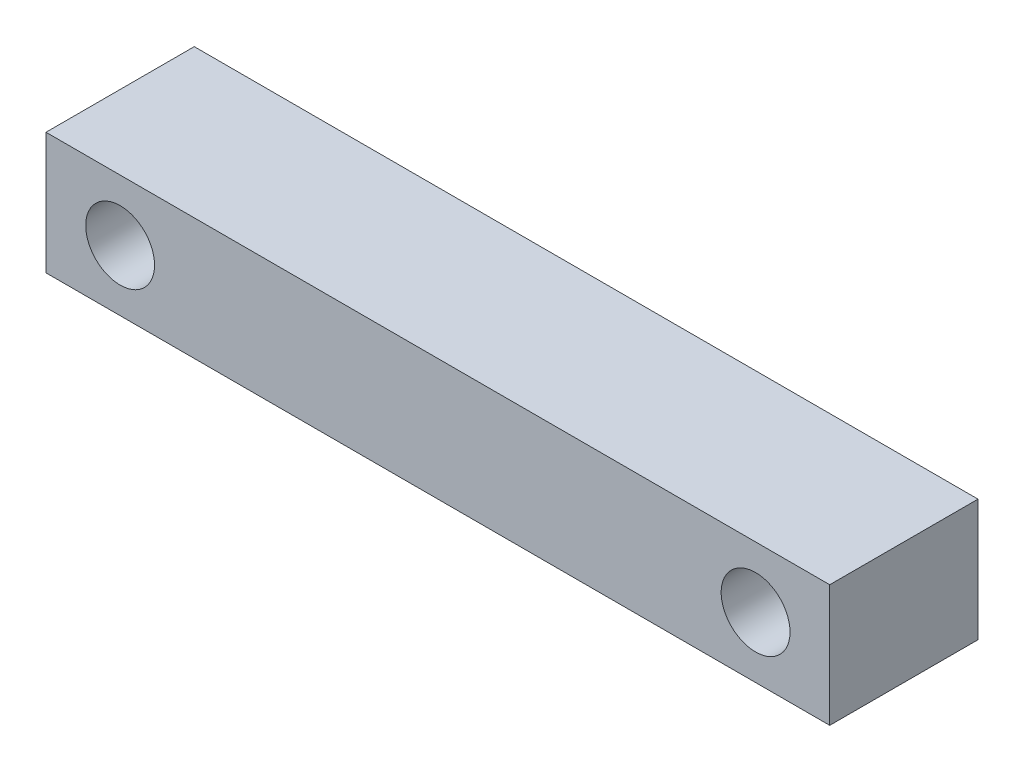
from build123d import *

# Parameters (mm, degrees)
SKETCH1_W      = 296
SKETCH1_H      = 46
SKETCH1_R      = 13
EXTRUDE1_DEPTH = 56


with BuildPart() as part:
    # Sketch1 → Extrude1 (new body)
    with BuildSketch(Plane.XY):
        with Locations((0, -23)):
            Rectangle(SKETCH1_W, SKETCH1_H)
        with Locations((-120, -23)):
            Circle(SKETCH1_R, mode=Mode.SUBTRACT)
        with Locations((120, -23)):
            Circle(SKETCH1_R, mode=Mode.SUBTRACT)
    extrude(amount=EXTRUDE1_DEPTH)


solid = part.part
